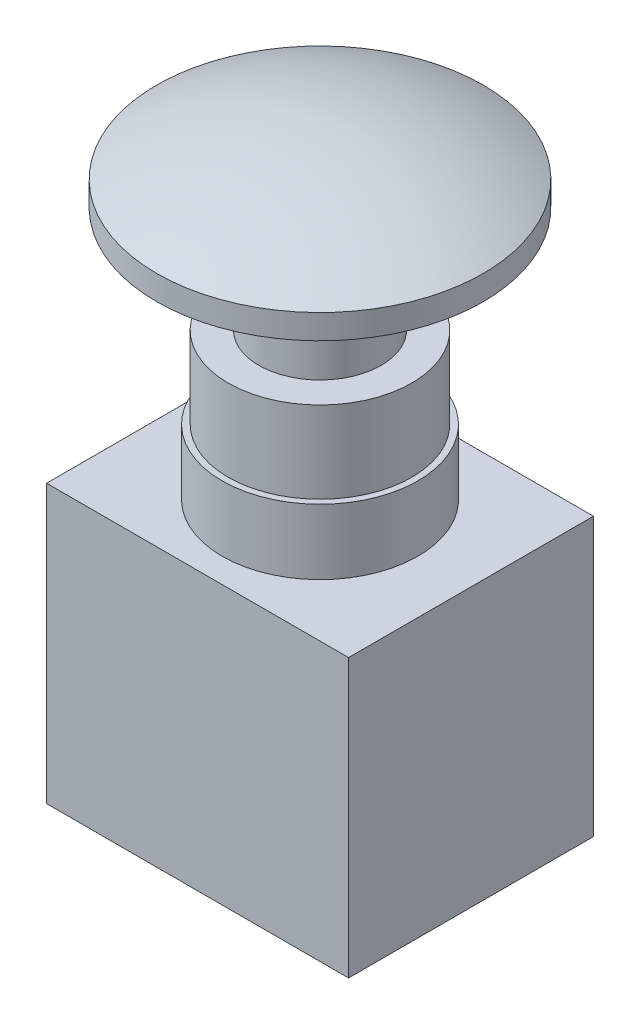
from build123d import *

# Parameters (mm, degrees)
SKETCH_1_W      = 37
SKETCH_1_H      = 30
EXTRUDE_1_DEPTH = 34
SKETCH_2_R      = 12
EXTRUDE_2_DEPTH = 8
SKETCH_3_R      = 11.25
EXTRUDE_3_DEPTH = 10


with BuildPart() as part:
    # Эскиз1 → Бобышка-Вытянуть1 (new body)
    with BuildSketch(Plane(origin=(0, 0, 0), x_dir=(1, 0, 0), z_dir=(0, 1, 0))):
        Rectangle(SKETCH_1_W, SKETCH_1_H)
    extrude(amount=-EXTRUDE_1_DEPTH)

    # Эскиз2 → Бобышка-Вытянуть2 (add)
    with BuildSketch(Plane(origin=(0, 0, 0), x_dir=(1, 0, 0), z_dir=(0, 1, 0))):
        Circle(SKETCH_2_R)
    extrude(amount=EXTRUDE_2_DEPTH)

    # Эскиз3 → Бобышка-Вытянуть3 (add)
    with BuildSketch(Plane(origin=(0, 8, 0), x_dir=(1, 0, 0), z_dir=(0, 1, 0))):
        Circle(SKETCH_3_R)
    extrude(amount=EXTRUDE_3_DEPTH)

    # Эскиз4 → Повернуть1 (revolve)
    with BuildSketch(Plane(origin=(0, 0, 0), x_dir=(0, 0, -1), z_dir=(1, 0, 0))):
        with BuildLine():
            Line((0, 18), (0, 39))
            ThreePointArc((0, 39), (10.307764064, 37.731056256), (20, 34))
            Line((20, 34), (20, 31))
            Line((20, 31), (11.5, 31))
            Line((11.5, 31), (11.5, 26))
            Line((11.5, 26), (7.5, 26))
            Line((7.5, 26), (7.5, 18))
            Line((7.5, 18), (0, 18))
        make_face()
    revolve(axis=Axis((0, -965.379937914, 0), (0, 1, 0)))


solid = part.part
